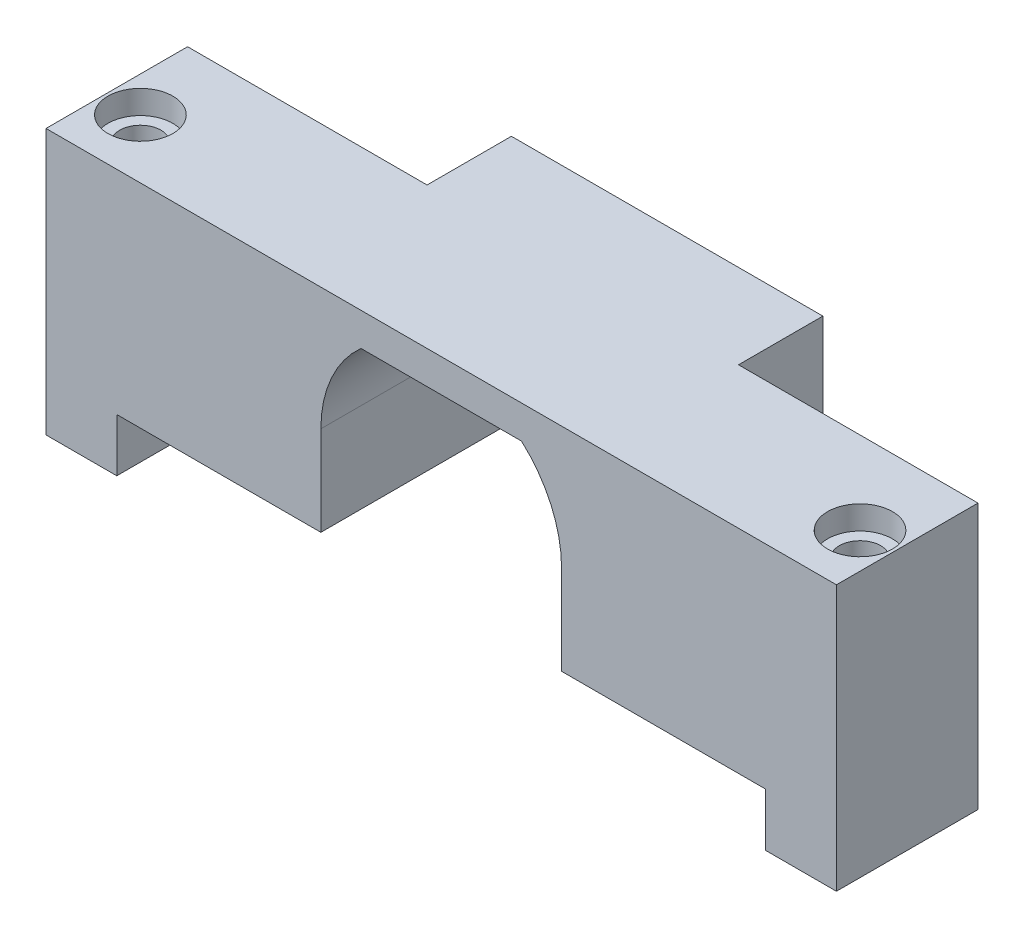
from build123d import *

# Parameters (mm, degrees)
BOSS_EXTRUDE2_DEPTH = 12
SKETCH2_W           = 12
SKETCH2_H           = 22.5
BOSS_EXTRUDE3_DEPTH = 6
SKETCH3_W           = 12
SKETCH3_H           = 22.5
BOSS_EXTRUDE4_DEPTH = 6
SKETCH4_R           = 1.75
CUT_EXTRUDE1_DEPTH  = 22.5
BOSS_EXTRUDE5_DEPTH = 4.65
SKETCH6_W           = 26.4
SKETCH6_H           = 18
SKETCH6_R           = 4.925
BOSS_EXTRUDE6_DEPTH = 2.5
SKETCH7_R           = 2.75
CUT_EXTRUDE2_DEPTH  = 2


with BuildPart() as part:
    # Sketch1 → Boss-Extrude2 (new body)
    with BuildSketch(Plane.XY):
        Polygon((0, 18), (0, 0), (17.3, 0), (17.3, 7.6), (17.3, 15.2), (20.697059459, 15.2), (34.302940541, 15.2), (37.7, 15.2), (37.7, 7.6), (37.7, 0), (55, 0), (55, 18), align=None)
        with BuildLine():
            Line((17.3, 15.2), (17.3, 7.6))
            ThreePointArc((17.3, 7.6), (18.187911257, 11.762331467), (20.697059459, 15.2))
            Line((20.697059459, 15.2), (17.3, 15.2))
        make_face()
        with BuildLine():
            Line((37.7, 15.2), (34.302940541, 15.2))
            ThreePointArc((34.302940541, 15.2), (36.812088743, 11.762331467), (37.7, 7.6))
            Line((37.7, 7.6), (37.7, 15.2))
        make_face()
    extrude(amount=BOSS_EXTRUDE2_DEPTH)

    # Sketch2 → Boss-Extrude3 (add)
    with BuildSketch(Plane.ZY):
        with Locations((6, 6.75)):
            Rectangle(SKETCH2_W, SKETCH2_H)
    extrude(amount=BOSS_EXTRUDE3_DEPTH)

    # Sketch3 → Boss-Extrude4 (add)
    with BuildSketch(Plane(origin=(55, 0, 0), x_dir=(0, 0, -1), z_dir=(1, 0, 0))):
        with Locations((-6, 6.75)):
            Rectangle(SKETCH3_W, SKETCH3_H)
    extrude(amount=BOSS_EXTRUDE4_DEPTH)

    # Sketch4 → Cut-Extrude1 (cut)
    with BuildSketch(Plane(origin=(0, 18, 0), x_dir=(1, 0, 0), z_dir=(0, 1, 0))):
        with Locations((-3, -7)):
            Circle(SKETCH4_R)
        with Locations((58, -7)):
            Circle(SKETCH4_R)
    extrude(amount=-CUT_EXTRUDE1_DEPTH, mode=Mode.SUBTRACT)

    # Sketch5 → Boss-Extrude5 (add)
    with BuildSketch(Plane(origin=(0, 0, 0), x_dir=(-1, 0, 0), z_dir=(0, 0, -1))):
        with BuildLine():
            Line((-37.7, 0), (-40.7, 0))
            Line((-40.7, 0), (-40.7, 18))
            Line((-40.7, 18), (-14.3, 18))
            Line((-14.3, 18), (-14.3, 0))
            Line((-14.3, 0), (-17.3, 0))
            Line((-17.3, 0), (-17.3, 6))
            ThreePointArc((-17.3, 6), (-18.898767331, 7.537206525), (-17.425490196, 9.195071224))
            ThreePointArc((-17.425490196, 9.195071224), (-18.543054375, 12.47986937), (-20.697059459, 15.2))
            Line((-20.697059459, 15.2), (-34.302940541, 15.2))
            ThreePointArc((-34.302940541, 15.2), (-36.456945625, 12.47986937), (-37.574509804, 9.195071224))
            ThreePointArc((-37.574509804, 9.195071224), (-36.101232669, 7.537206525), (-37.7, 6))
            Line((-37.7, 6), (-37.7, 0))
        make_face()
    extrude(amount=BOSS_EXTRUDE5_DEPTH)

    # Sketch6 → Boss-Extrude6 (add)
    with BuildSketch(Plane(origin=(0, 0, -4.65), x_dir=(-1, 0, 0), z_dir=(0, 0, -1))):
        with Locations((-27.5, 9)):
            Rectangle(SKETCH6_W, SKETCH6_H)
        with Locations((-27.5, 7.537206525)):
            Circle(SKETCH6_R, mode=Mode.SUBTRACT)
    extrude(amount=BOSS_EXTRUDE6_DEPTH)

    # Sketch7 → Cut-Extrude2 (cut)
    with BuildSketch(Plane(origin=(0, 18, 0), x_dir=(1, 0, 0), z_dir=(0, 1, 0))):
        with Locations((-3, -7)):
            Circle(SKETCH7_R)
        with Locations((58, -7)):
            Circle(SKETCH7_R)
    extrude(amount=-CUT_EXTRUDE2_DEPTH, mode=Mode.SUBTRACT)


solid = part.part
